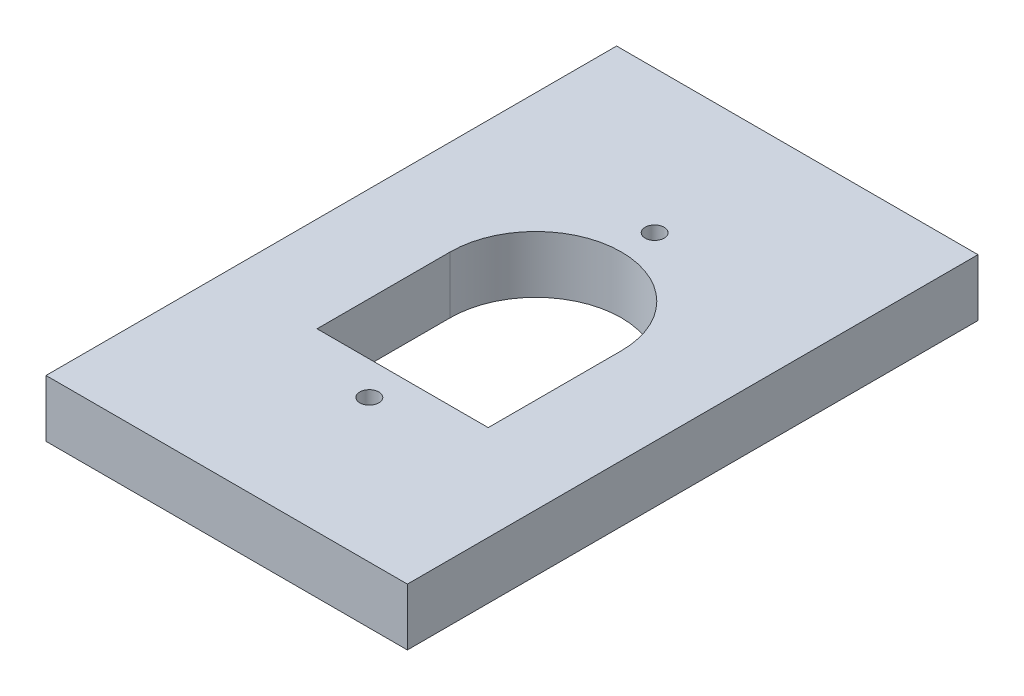
from build123d import *

# Parameters (mm, degrees)
SKETCH1_W           = 19
SKETCH1_H           = 30
BOSS_EXTRUDE1_DEPTH = 3
SKETCH2_R           = 0.5
CUT_EXTRUDE1_DEPTH  = 4


with BuildPart() as part:
    # Sketch1 → Boss-Extrude1 (new body)
    with BuildSketch(Plane(origin=(0, 0, 0), x_dir=(1, 0, 0), z_dir=(0, 1, 0))):
        with Locations((9.5, -15)):
            Rectangle(SKETCH1_W, SKETCH1_H)
    extrude(amount=BOSS_EXTRUDE1_DEPTH)

    # Sketch2 → Cut-Extrude1 (cut, through all)
    with BuildSketch(Plane(origin=(0, 3, 0), x_dir=(1, 0, 0), z_dir=(0, 1, 0))):
        with BuildLine():
            Line((5, -20.75), (14, -20.75))
            Line((14, -20.75), (14, -13.75))
            ThreePointArc((14, -13.75), (9.5, -9.25), (5, -13.75))
            Line((5, -13.75), (5, -20.75))
        make_face()
        with Locations((9.5, -22.5)):
            Circle(SKETCH2_R)
        with Locations((9.5, -7.5)):
            Circle(SKETCH2_R)
    extrude(amount=-CUT_EXTRUDE1_DEPTH, mode=Mode.SUBTRACT)


solid = part.part
